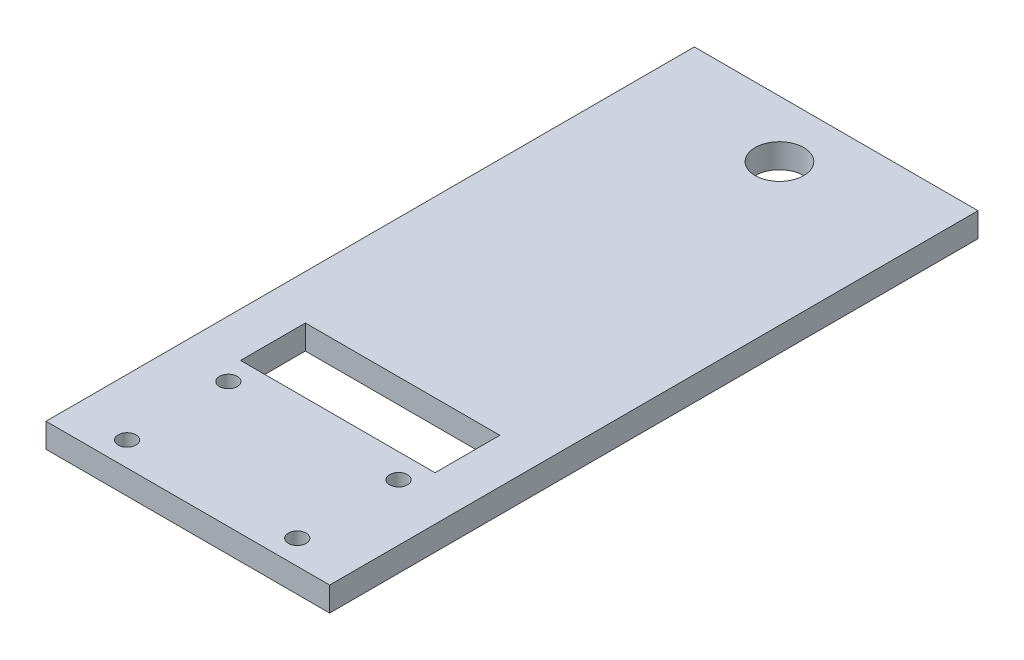
from build123d import *

# Parameters (mm, degrees)
SKETCH1_W           = 35
SKETCH1_H           = 80
SKETCH1_R           = 1.1
BOSS_EXTRUDE1_DEPTH = 3
SKETCH2_R           = 3
CUT_EXTRUDE1_DEPTH  = 4
SKETCH3_W           = 24
SKETCH3_H           = 8
CUT_EXTRUDE2_DEPTH  = 4


with BuildPart() as part:
    # Sketch1 → Boss-Extrude1 (new body)
    with BuildSketch(Plane(origin=(0, 0, 0), x_dir=(1, 0, 0), z_dir=(0, 1, 0))):
        with Locations((17.5, 40)):
            Rectangle(SKETCH1_W, SKETCH1_H)
        with Locations((7, 3)):
            Circle(SKETCH1_R, mode=Mode.SUBTRACT)
        with Locations((28, 3)):
            Circle(SKETCH1_R, mode=Mode.SUBTRACT)
        with Locations((7, 15.5)):
            Circle(SKETCH1_R, mode=Mode.SUBTRACT)
        with Locations((28, 15.5)):
            Circle(SKETCH1_R, mode=Mode.SUBTRACT)
    extrude(amount=BOSS_EXTRUDE1_DEPTH)

    # Sketch2 → Cut-Extrude1 (cut, through all)
    with BuildSketch(Plane.XZ):
        with Locations((17.5, -73)):
            Circle(SKETCH2_R)
    extrude(amount=-CUT_EXTRUDE1_DEPTH, mode=Mode.SUBTRACT)

    # Sketch3 → Cut-Extrude2 (cut, through all)
    with BuildSketch(Plane(origin=(0, 3, 0), x_dir=(1, 0, 0), z_dir=(0, 1, 0))):
        with Locations((17.5, 22.5)):
            Rectangle(SKETCH3_W, SKETCH3_H)
    extrude(amount=-CUT_EXTRUDE2_DEPTH, mode=Mode.SUBTRACT)


solid = part.part
